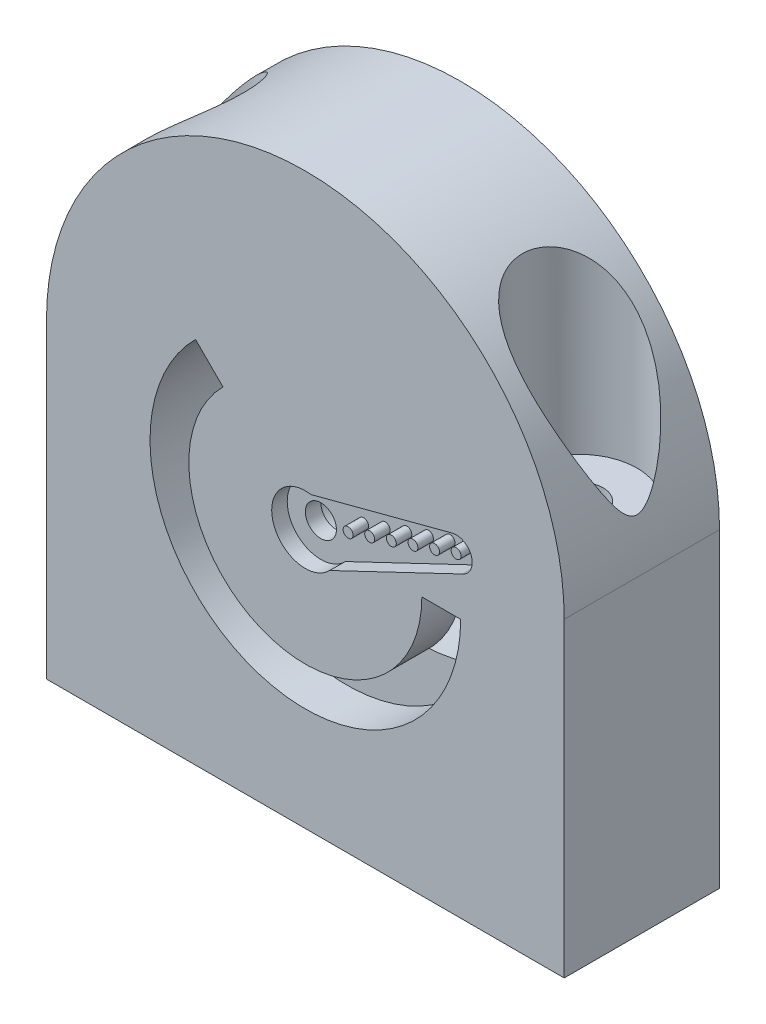
from build123d import *

# Parameters (mm, degrees)
BOSS_EXTRUDE1_DEPTH = 15
CUT_EXTRUDE1_REACH  = 57
SKETCH2_R           = 2.25
SKETCH3_R           = 5.54
CUT_EXTRUDE2_DEPTH  = 21
SKETCH4_W           = 24
SKETCH4_H           = 7
CUT_EXTRUDE3_DEPTH  = 29
CUT_EXTRUDE4_REACH  = 17
CUT_EXTRUDE5_DEPTH  = 1.5
SKETCH7_R           = 3.25
BOSS_EXTRUDE2_DEPTH = 13.5
CUT_EXTRUDE6_REACH  = 15.5
SKETCH8_R           = 1.5
SKETCH9_R           = 2.5
CUT_EXTRUDE7_DEPTH  = 12
SKETCH10_R          = 0.48
BOSS_EXTRUDE3_DEPTH = 1.5


with BuildPart() as part:
    # Sketch1 → Boss-Extrude1 (new body)
    with BuildSketch(Plane.XY):
        with BuildLine():
            Line((25, 0), (25, -30))
            Line((25, -30), (-25, -30))
            Line((-25, -30), (-25, 0))
            ThreePointArc((-25, 0), (0, 25), (25, 0))
        make_face()
    extrude(amount=BOSS_EXTRUDE1_DEPTH)

    # Sketch2 → Cut-Extrude1 (cut, up to next)
    with BuildSketch(Plane.XZ.offset(30), mode=Mode.PRIVATE) as cut_extrude1_sk1:
        with Locations((-19, 7.5)):
            Circle(SKETCH2_R)
    cut_extrude1_tool1 = extrude(cut_extrude1_sk1.sketch, amount=-CUT_EXTRUDE1_REACH, mode=Mode.PRIVATE) & part.part
    add(cut_extrude1_tool1.solids().sort_by_distance((-19, -30, 7.5))[0], mode=Mode.SUBTRACT)
    # Sketch2 → Cut-Extrude1 (cut, up to next)
    with BuildSketch(Plane.XZ.offset(30), mode=Mode.PRIVATE) as cut_extrude1_sk2:
        with Locations((19, 7.5)):
            Circle(SKETCH2_R)
    cut_extrude1_tool2 = extrude(cut_extrude1_sk2.sketch, amount=-CUT_EXTRUDE1_REACH, mode=Mode.PRIVATE) & part.part
    add(cut_extrude1_tool2.solids().sort_by_distance((19, -30, 7.5))[0], mode=Mode.SUBTRACT)

    # Sketch3 → Cut-Extrude2 (cut)
    with BuildSketch(Plane(origin=(0, 24.127056635, 0), x_dir=(1, 0, 0), z_dir=(0, 1, 0))):
        with Locations((19, -7.5)):
            Circle(SKETCH3_R)
        with Locations((-19, -7.5)):
            Circle(SKETCH3_R)
    extrude(amount=-CUT_EXTRUDE2_DEPTH, mode=Mode.SUBTRACT)

    # Sketch4 → Cut-Extrude3 (cut)
    with BuildSketch(Plane.XZ.offset(30)):
        with Locations((0, 7.5)):
            Rectangle(SKETCH4_W, SKETCH4_H)
    extrude(amount=-CUT_EXTRUDE3_DEPTH, mode=Mode.SUBTRACT)

    # Sketch5 → Cut-Extrude4 (cut, up to next)
    with BuildSketch(Plane.XY.offset(15), mode=Mode.PRIVATE) as cut_extrude4_sk1:
        with BuildLine():
            Line((11.251747285, -5), (15, -5))
            ThreePointArc((15, -5), (0, -20), (-15, -5))
            ThreePointArc((-15, -5), (-13.858192988, 0.740251485), (-10.606601718, 5.606601718))
            Line((-10.606601718, 5.606601718), (-7.956186805, 2.956186805))
            ThreePointArc((-7.956186805, 2.956186805), (-10.395259022, -0.694142729), (-11.251747285, -5))
            ThreePointArc((-11.251747285, -5), (0, -16.251747285), (11.251747285, -5))
        make_face()
    cut_extrude4_tool1 = extrude(cut_extrude4_sk1.sketch, amount=-CUT_EXTRUDE4_REACH, mode=Mode.PRIVATE) & part.part
    add(cut_extrude4_tool1.solids().sort_by_distance((13.125874, -5.394423, 15))[0], mode=Mode.SUBTRACT)

    # Sketch6 → Cut-Extrude5 (cut)
    with BuildSketch(Plane.XY.offset(15)):
        with BuildLine():
            Line((0.541549319, -1.795436951), (14.169837516, 1.800031788))
            ThreePointArc((14.169837516, 1.800031788), (16.028383105, 0.812877901), (15.18982596, -1.117274015))
            Line((15.18982596, -1.117274015), (2.352905683, -7.241948894))
            ThreePointArc((2.352905683, -7.241948894), (-3.083924533, -6.02562638), (0.541549319, -1.795436951))
        make_face()
    extrude(amount=-CUT_EXTRUDE5_DEPTH, mode=Mode.SUBTRACT)

    # Sketch7 → Boss-Extrude2 (add)
    with BuildSketch(Plane.XY.offset(13.5)):
        with Locations((0, -5)):
            Circle(SKETCH7_R)
    extrude(amount=-BOSS_EXTRUDE2_DEPTH)

    # Sketch8 → Cut-Extrude6 (cut, up to next)
    with BuildSketch(Plane.XY.offset(13.5), mode=Mode.PRIVATE) as cut_extrude6_sk1:
        with Locations((0, -5)):
            Circle(SKETCH8_R)
    cut_extrude6_tool1 = extrude(cut_extrude6_sk1.sketch, amount=-CUT_EXTRUDE6_REACH, mode=Mode.PRIVATE) & part.part
    add(cut_extrude6_tool1.solids().sort_by_distance((0, -5, 13.5))[0], mode=Mode.SUBTRACT)

    # Sketch9 → Cut-Extrude7 (cut)
    with BuildSketch(Plane(origin=(0, 0, 0), x_dir=(-1, 0, 0), z_dir=(0, 0, -1))):
        with Locations((0, -5)):
            Circle(SKETCH9_R)
    extrude(amount=-CUT_EXTRUDE7_DEPTH, mode=Mode.SUBTRACT)

    # Sketch10 → Boss-Extrude3 (add)
    with BuildSketch(Plane.XY.offset(13.5)):
        with Locations((14.565235622, 0.301312222)):
            Circle(SKETCH10_R)
        with Locations((12.477655938, -0.392957944)):
            Circle(SKETCH10_R)
        with Locations((10.390076254, -1.087228109)):
            Circle(SKETCH10_R)
        with Locations((8.30249657, -1.781498274)):
            Circle(SKETCH10_R)
        with Locations((6.214916885, -2.475768439)):
            Circle(SKETCH10_R)
        with Locations((4.127337201, -3.170038604)):
            Circle(SKETCH10_R)
    extrude(amount=BOSS_EXTRUDE3_DEPTH)


solid = part.part
